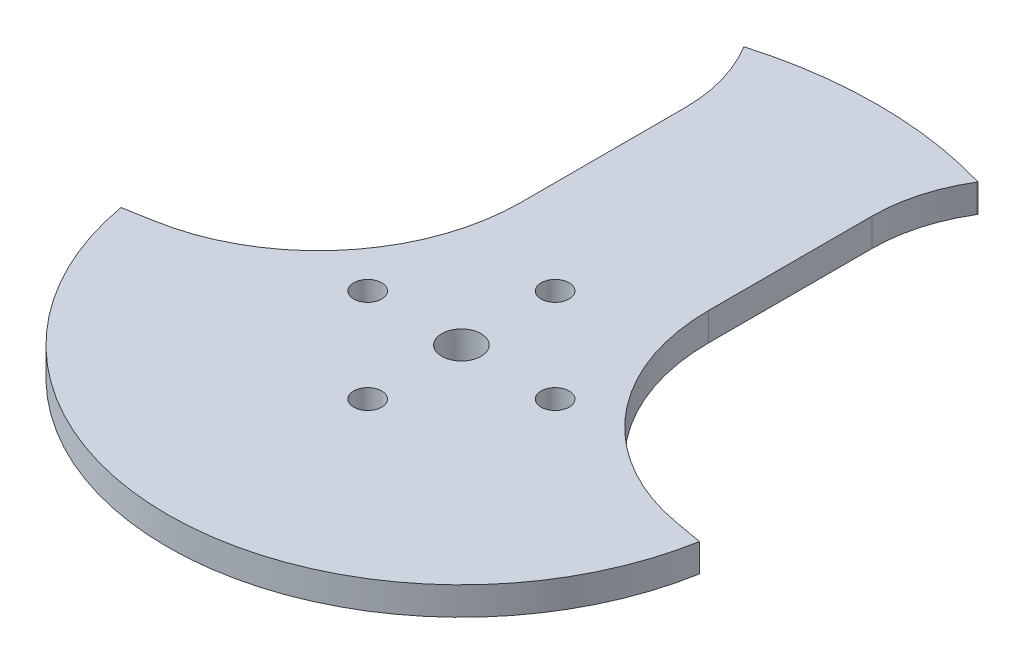
from build123d import *

# Parameters (mm, degrees)
BOSS_EXTRUDE1_DEPTH = 3
SKETCH2_R           = 2.1
SKETCH2_R_2         = 1.5
CUT_EXTRUDE1_DEPTH  = 55.203222002


with BuildPart() as part:
    # Sketch1 → Boss-Extrude1 (new body)
    with BuildSketch(Plane(origin=(0, 0, 0), x_dir=(1, 0, 0), z_dir=(0, 1, 0))):
        with BuildLine():
            Line((-12.5, 42.656212912), (-12.447999296, 42.570796715))
            ThreePointArc((-12.447999296, 42.570796715), (-10.623582733, 38.374834362), (-10, 33.842093422))
            Line((-10, 33.842093422), (-10, 16.408985467))
            ThreePointArc((-10, 16.408985467), (-15.066740521, 2.488230295), (-27.896177884, -4.91884882))
            Line((-27.896177884, -4.91884882), (-30.873723057, -5.44387037))
            ThreePointArc((-30.873723057, -5.44387037), (0, -31.35), (30.873723057, -5.44387037))
            Line((30.873723057, -5.44387037), (27.896177884, -4.91884882))
            ThreePointArc((27.896177884, -4.91884882), (15.066740521, 2.488230295), (10, 16.408985467))
            Line((10, 16.408985467), (10, 33.842093422))
            ThreePointArc((10, 33.842093422), (10.623582733, 38.374834362), (12.447999296, 42.570796715))
            Line((12.447999296, 42.570796715), (12.5, 42.656212912))
            ThreePointArc((12.5, 42.656212912), (0, 44.45), (-12.5, 42.656212912))
        make_face()
    extrude(amount=BOSS_EXTRUDE1_DEPTH)

    # Sketch2 → Cut-Extrude1 (cut, through all)
    with BuildSketch(Plane(origin=(0, 3, 0), x_dir=(1, 0, 0), z_dir=(0, 1, 0))):
        with Locations((0, 0.014087551)):
            Circle(SKETCH2_R)
        with Locations((10, 0.014087551)):
            Circle(SKETCH2_R_2)
        with Locations((0, 10.014087551)):
            Circle(SKETCH2_R_2)
        with Locations((-10, 0.014087551)):
            Circle(SKETCH2_R_2)
        with Locations((0, -9.985912449)):
            Circle(SKETCH2_R_2)
    extrude(amount=-CUT_EXTRUDE1_DEPTH, mode=Mode.SUBTRACT)


solid = part.part
